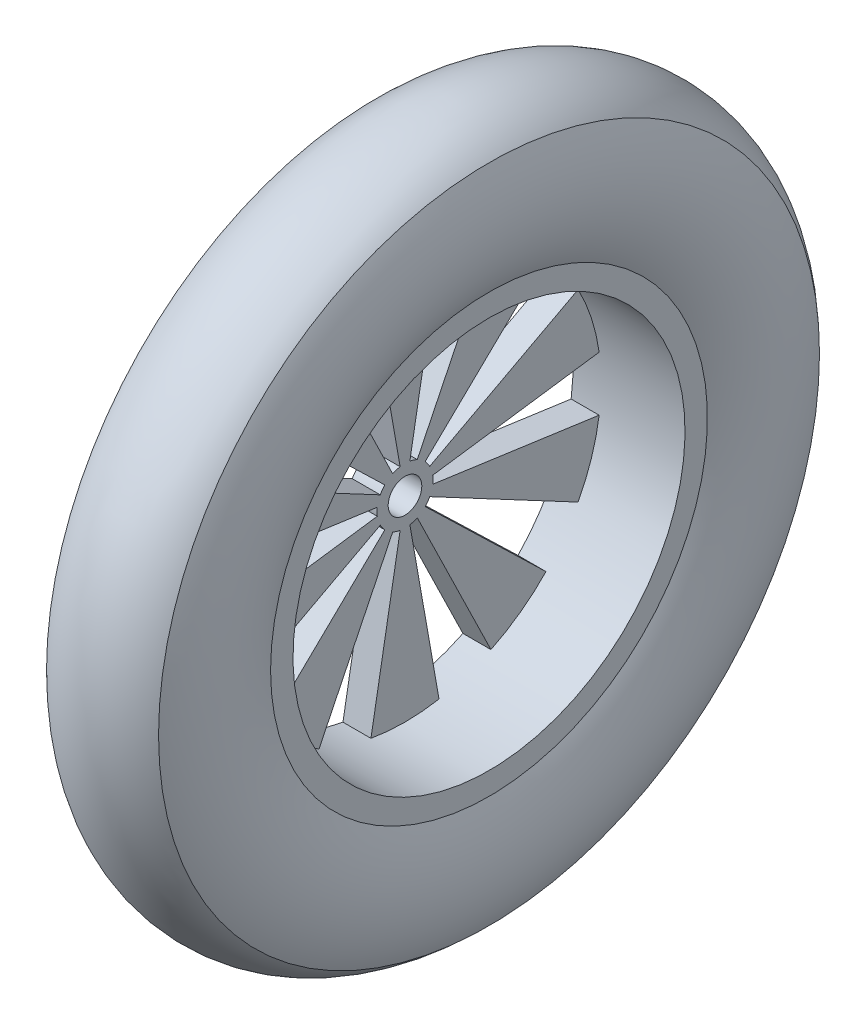
from build123d import *

# Parameters (mm, degrees)
SKETCH4_R           = 6
BOSS_EXTRUDE2_DEPTH = 10


with BuildPart() as part:
    # Sketch1 → Revolve1 (revolve)
    with BuildSketch(Plane.XY):
        Polygon((18, 78), (20, 78), (20, 70), (0, 70), (-20, 70), (-20, 78), (-18, 78), (-18, 72), (0, 72), (18, 72), align=None)
    revolve(axis=Axis((0, 0, 0), (-1, 0, 0)))

    # Sketch2 → Revolve2 (revolve)
    with BuildSketch(Plane.XY):
        with BuildLine():
            Line((-20, 78), (20, 78))
            ThreePointArc((20, 78), (24.688711259, 98), (20, 118))
            ThreePointArc((20, 118), (0, 126.284271247), (-20, 118))
            ThreePointArc((-20, 118), (-24.688711259, 98), (-20, 78))
        make_face()
    revolve(axis=Axis((-54.573590753, 0, 0), (1, 0, 0)))

    # Sketch4 → Boss-Extrude2 (add)
    with BuildSketch(Plane.ZY.offset(20)):
        with BuildLine():
            Line((4.383711468, 8.987940463), (30.685980275, 62.915583241))
            ThreePointArc((30.685980275, 62.915583241), (41.14496766, 56.631189606), (50.353786024, 48.626085932))
            Line((50.353786024, 48.626085932), (7.193398003, 6.946583705))
            ThreePointArc((7.193398003, 6.946583705), (8.090169944, 5.877852523), (8.829475929, 4.694715628))
            Line((8.829475929, 4.694715628), (61.8063315, 32.863009395))
            ThreePointArc((61.8063315, 32.863009395), (66.573956141, 21.631189606), (69.318764812, 9.742117067))
            Line((69.318764812, 9.742117067), (9.902680687, 1.39173101))
            ThreePointArc((9.902680687, 1.39173101), (10, 0), (9.902680687, -1.39173101))
            Line((9.902680687, -1.39173101), (69.318764812, -9.742117067))
            ThreePointArc((69.318764812, -9.742117067), (66.573956141, -21.631189606), (61.8063315, -32.863009395))
            Line((61.8063315, -32.863009395), (8.829475929, -4.694715628))
            ThreePointArc((8.829475929, -4.694715628), (8.090169944, -5.877852523), (7.193398003, -6.946583705))
            Line((7.193398003, -6.946583705), (50.353786024, -48.626085932))
            ThreePointArc((50.353786024, -48.626085932), (41.14496766, -56.631189606), (30.685980275, -62.915583241))
            Line((30.685980275, -62.915583241), (4.383711468, -8.987940463))
            ThreePointArc((4.383711468, -8.987940463), (3.090169944, -9.510565163), (1.736481777, -9.84807753))
            Line((1.736481777, -9.84807753), (12.155372437, -68.936542711))
            ThreePointArc((12.155372437, -68.936542711), (0, -70), (-12.155372437, -68.936542711))
            Line((-12.155372437, -68.936542711), (-1.736481777, -9.84807753))
            ThreePointArc((-1.736481777, -9.84807753), (-3.090169944, -9.510565163), (-4.383711468, -8.987940463))
            Line((-4.383711468, -8.987940463), (-30.685980275, -62.915583241))
            ThreePointArc((-30.685980275, -62.915583241), (-41.14496766, -56.631189606), (-50.353786024, -48.626085932))
            Line((-50.353786024, -48.626085932), (-7.193398003, -6.946583705))
            ThreePointArc((-7.193398003, -6.946583705), (-8.090169944, -5.877852523), (-8.829475929, -4.694715628))
            Line((-8.829475929, -4.694715628), (-61.8063315, -32.863009395))
            ThreePointArc((-61.8063315, -32.863009395), (-66.573956141, -21.631189606), (-69.318764812, -9.742117067))
            Line((-69.318764812, -9.742117067), (-9.902680687, -1.39173101))
            ThreePointArc((-9.902680687, -1.39173101), (-10, 0), (-9.902680687, 1.39173101))
            Line((-9.902680687, 1.39173101), (-69.318764812, 9.742117067))
            ThreePointArc((-69.318764812, 9.742117067), (-66.573956141, 21.631189606), (-61.8063315, 32.863009395))
            Line((-61.8063315, 32.863009395), (-8.829475929, 4.694715628))
            ThreePointArc((-8.829475929, 4.694715628), (-8.090169944, 5.877852523), (-7.193398003, 6.946583705))
            Line((-7.193398003, 6.946583705), (-50.353786024, 48.626085932))
            ThreePointArc((-50.353786024, 48.626085932), (-41.14496766, 56.631189606), (-30.685980275, 62.915583241))
            Line((-30.685980275, 62.915583241), (-4.383711468, 8.987940463))
            ThreePointArc((-4.383711468, 8.987940463), (-3.090169944, 9.510565163), (-1.736481777, 9.84807753))
            Line((-1.736481777, 9.84807753), (-12.155372437, 68.936542711))
            ThreePointArc((-12.155372437, 68.936542711), (0, 70), (12.155372437, 68.936542711))
            Line((12.155372437, 68.936542711), (1.736481777, 9.84807753))
            ThreePointArc((1.736481777, 9.84807753), (3.090169944, 9.510565163), (4.383711468, 8.987940463))
        make_face()
        Circle(SKETCH4_R, mode=Mode.SUBTRACT)
    extrude(amount=-BOSS_EXTRUDE2_DEPTH)


solid = part.part
